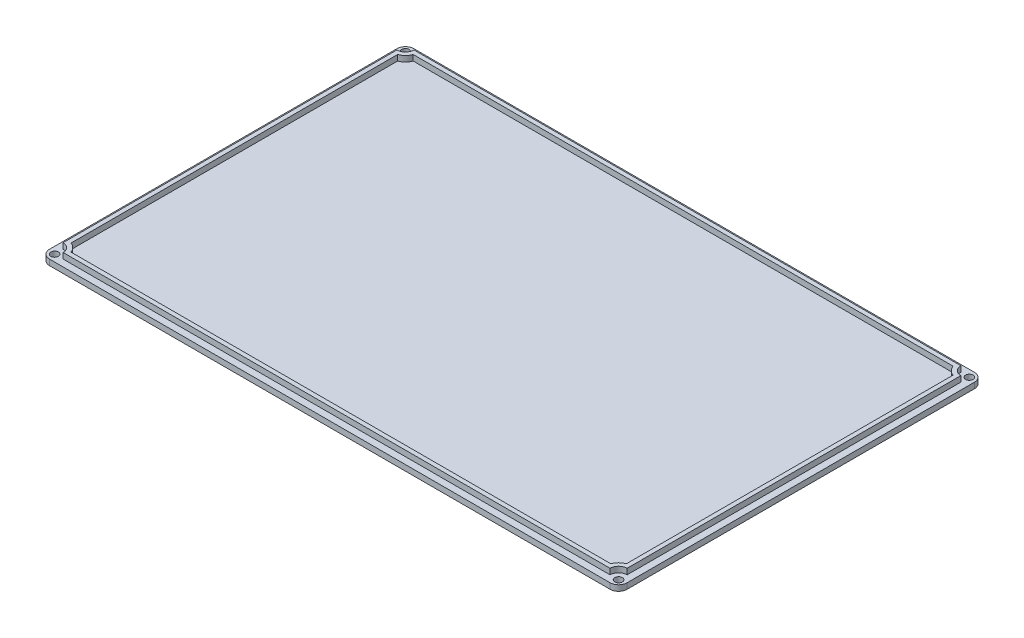
from build123d import *

# Parameters (mm, degrees)
SKETCH20_W            = 172.0559932
SKETCH20_H            = 108.5559932
BOSS_EXTRUDE5_DEPTH   = 1.699999902
BOSS_EXTRUDE6_DEPTH   = 1.7
FILLET3_R             = 2.54
F_4_40_TAPPED_HOLE3_D = 2.2606


with BuildPart() as part:
    # Sketch20 → Boss-Extrude5 (new body)
    with BuildSketch(Plane(origin=(0, 0, 0), x_dir=(1, 0, 0), z_dir=(0, 1, 0))):
        with Locations((84.0279966, 74.0579966)):
            Rectangle(SKETCH20_W, SKETCH20_H)
    extrude(amount=-BOSS_EXTRUDE5_DEPTH)

    # Sketch20_3 → Boss-Extrude6 (add)
    with BuildSketch(Plane(origin=(0, 0, 0), x_dir=(1, 0, 0), z_dir=(0, 1, 0))):
        with BuildLine():
            Line((2.572, 21.812), (165.4839932, 21.812))
            ThreePointArc((165.4839932, 21.812), (166.227941976, 23.608051224), (168.0239932, 24.352))
            Line((168.0239932, 24.352), (168.0239932, 123.7639932))
            ThreePointArc((168.0239932, 123.7639932), (166.227941976, 124.507941976), (165.4839932, 126.3039932))
            Line((165.4839932, 126.3039932), (2.572, 126.3039932))
            ThreePointArc((2.572, 126.3039932), (1.828051224, 124.507941976), (0.032, 123.7639932))
            Line((0.032, 123.7639932), (0.032, 24.352))
            ThreePointArc((0.032, 24.352), (1.828051224, 23.608051224), (2.572, 21.812))
        make_face()
        with BuildLine():
            Line((3.624102448, 23.082), (164.431890752, 23.082))
            ThreePointArc((164.431890752, 23.082), (165.329916364, 24.506076836), (166.7539932, 25.404102448))
            Line((166.7539932, 25.404102448), (166.7539932, 122.711890752))
            ThreePointArc((166.7539932, 122.711890752), (165.329916364, 123.609916364), (164.431890752, 125.0339932))
            Line((164.431890752, 125.0339932), (3.624102448, 125.0339932))
            ThreePointArc((3.624102448, 125.0339932), (2.726076836, 123.609916364), (1.302, 122.711890752))
            Line((1.302, 122.711890752), (1.302, 25.404102448))
            ThreePointArc((1.302, 25.404102448), (2.726076836, 24.506076836), (3.624102448, 23.082))
        make_face(mode=Mode.SUBTRACT)
    extrude(amount=BOSS_EXTRUDE6_DEPTH)

    # Fillet3
    fillet3_edges = [part.edges().sort_by_distance(p)[0] for p in [
        (-2, -0.849999951, -19.78),
        (-2, -0.849999951, -128.3359932),
        (170.0559932, -0.849999951, -128.3359932),
        (170.0559932, -0.849999951, -19.78),
    ]]
    fillet(fillet3_edges, radius=FILLET3_R)

    # 4-40 Tapped Hole3 (through all)
    with Locations(Plane(origin=(0, 0, 0), x_dir=(1, 0, 0), z_dir=(0, 1, 0))):
        with Locations((0.032, 21.812), (168.0239932, 21.812), (168.0239932, 126.3039932), (0.032, 126.3039932)):
            Hole(F_4_40_TAPPED_HOLE3_D / 2)


solid = part.part
